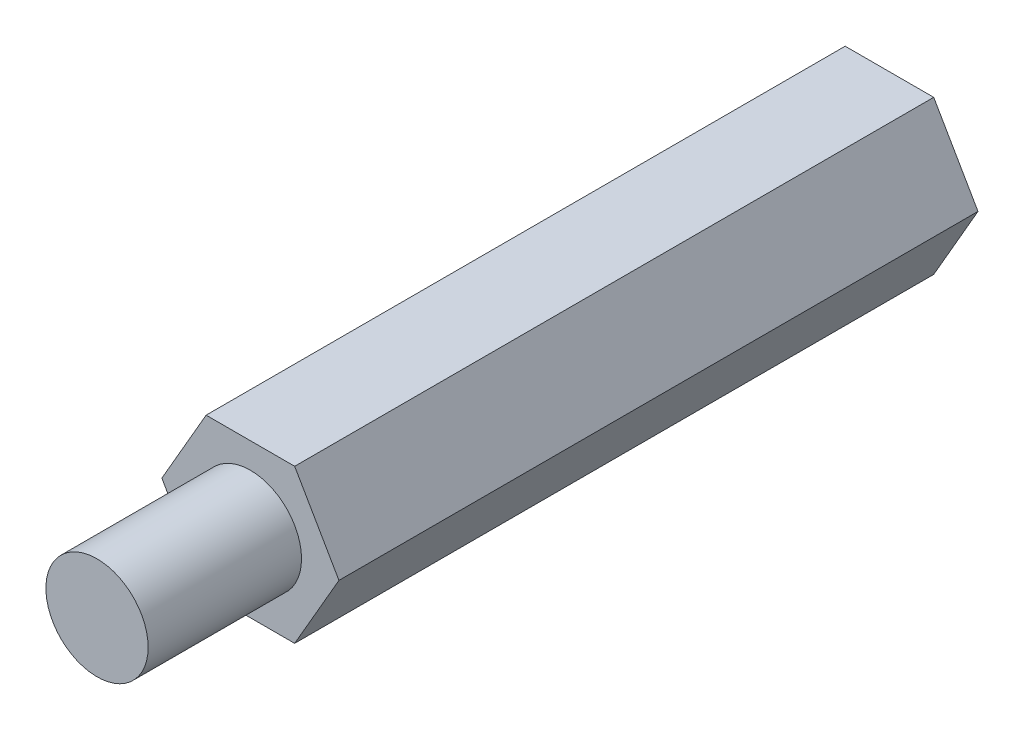
from build123d import *

# Parameters (mm, degrees)
BOSS_EXTRUDE1_DEPTH       = 25
SKETCH2_R                 = 2
BOSS_EXTRUDE2_DEPTH       = 6
M4X0_7_TAPPED_HOLE1_D     = 3.3
M4X0_7_TAPPED_HOLE1_DEPTH = 10.1
M4X0_7_TAPPED_HOLE1_TIP   = 0.991420021


with BuildPart() as part:
    # Sketch1 → Boss-Extrude1 (new body)
    with BuildSketch(Plane.XY):
        Polygon((3.464101615, 0), (1.732050808, 3), (-1.732050808, 3), (-3.464101615, 0), (-1.732050808, -3), (1.732050808, -3), align=None)
    extrude(amount=BOSS_EXTRUDE1_DEPTH)

    # Sketch2 → Boss-Extrude2 (add)
    with BuildSketch(Plane.XY.offset(25)):
        Circle(SKETCH2_R)
    extrude(amount=BOSS_EXTRUDE2_DEPTH)

    # M4x0.7 Tapped Hole1
    with Locations(Plane(origin=(0, 0, 0), x_dir=(-1, 0, 0), z_dir=(0, 0, -1))):
        with Locations((0, 0)):
            Hole(M4X0_7_TAPPED_HOLE1_D / 2, depth=M4X0_7_TAPPED_HOLE1_DEPTH)
            with Locations((0, 0, -(M4X0_7_TAPPED_HOLE1_DEPTH + M4X0_7_TAPPED_HOLE1_TIP / 2))):  # 118° drill point
                Cone(0, M4X0_7_TAPPED_HOLE1_D / 2, M4X0_7_TAPPED_HOLE1_TIP, mode=Mode.SUBTRACT)


solid = part.part
